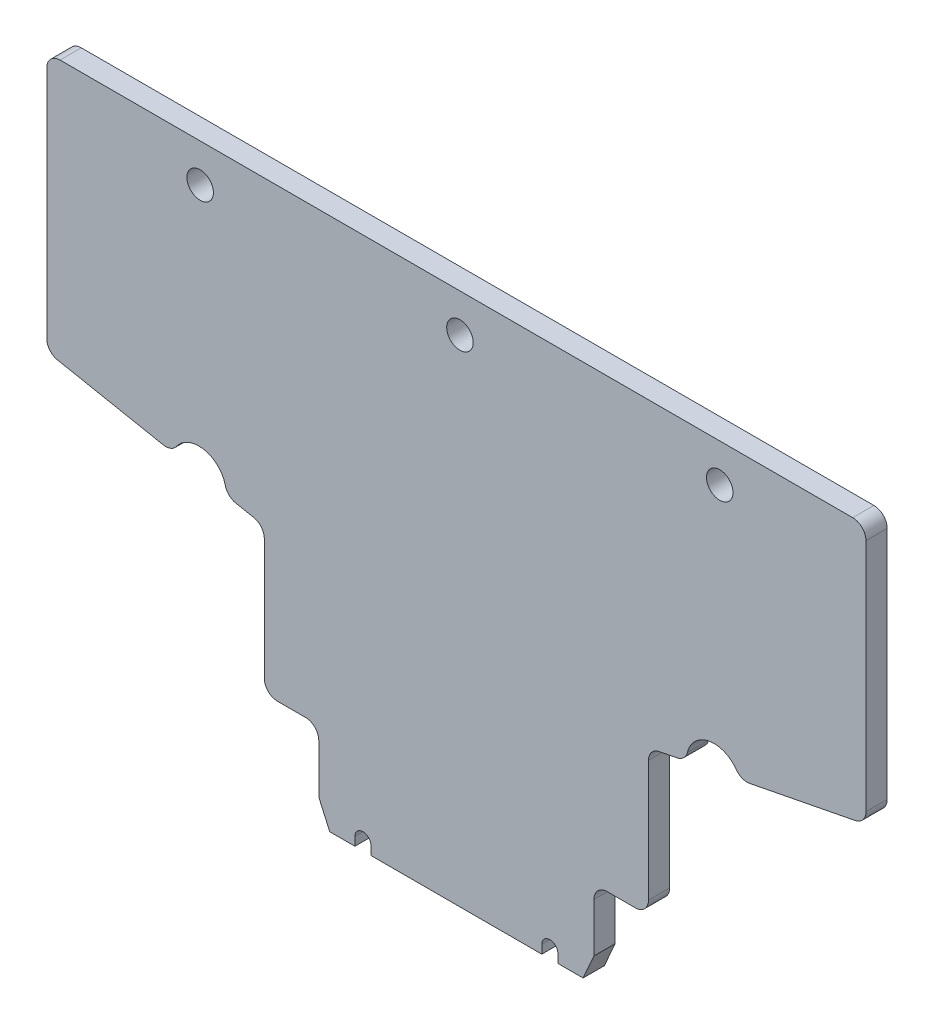
from build123d import *

# Parameters (mm, degrees)
SKETCH1_W           = 80
SKETCH1_H           = 60
BOSS_EXTRUDE1_DEPTH = 1.6
SKETCH2_OUTSIDE_W   = 102.002
SKETCH2_OUTSIDE_H   = 82.002
CUT_EXTRUDE1_DEPTH  = 1.6
FILLET1_R           = 1
SKETCH3_R           = 1
CUT_EXTRUDE2_DEPTH  = 10


with BuildPart() as part:
    # Sketch1 → Boss-Extrude1 (new body)
    with BuildSketch(Plane.XY):
        with Locations((40, 30)):
            Rectangle(SKETCH1_W, SKETCH1_H)
    extrude(amount=BOSS_EXTRUDE1_DEPTH)

    # Sketch2 outside → Cut-Extrude1 (cut)
    with BuildSketch(Plane.XY.offset(1.6)):
        with Locations((40, 30)):
            Rectangle(SKETCH2_OUTSIDE_W, SKETCH2_OUTSIDE_H)
        with BuildLine():
            Line((8.830524125, 49.648617791), (70.632878184, 49.648617791))
            Line((70.632878184, 49.648617791), (70.632878184, 30.112540158))
            Line((70.632878184, 30.112540158), (61.123106489, 28.255784683))
            ThreePointArc((61.123106489, 28.255784683), (58.77201565, 29.627241667), (57.109476194, 27.472134952))
            Line((57.109476194, 27.472134952), (54.224418996, 26.908835862))
            Line((54.224418996, 26.908835862), (54.224418996, 15.955223451))
            Line((54.224418996, 15.955223451), (50.114060899, 15.955223451))
            Line((50.114060899, 15.955223451), (50.114060899, 11.256501231))
            Line((50.114060899, 11.256501231), (49.289397665, 9.401008955))
            Line((49.289397665, 9.401008955), (47.389901446, 9.401008955))
            Line((47.389901446, 9.401008955), (47.389901446, 10.047799846))
            ThreePointArc((47.389901446, 10.047799846), (46.783221619, 10.654479673), (46.176541793, 10.047799846))
            Line((46.176541793, 10.047799846), (46.176541793, 9.401008955))
            Line((46.176541793, 9.401008955), (33.286860516, 9.401008955))
            Line((33.286860516, 9.401008955), (33.286860516, 10.047799846))
            ThreePointArc((33.286860516, 10.047799846), (32.68018069, 10.654479673), (32.073500863, 10.047799846))
            Line((32.073500863, 10.047799846), (32.073500863, 9.401008955))
            Line((32.073500863, 9.401008955), (30.174004644, 9.401008955))
            Line((30.174004644, 9.401008955), (29.34934141, 11.256501231))
            Line((29.34934141, 11.256501231), (29.34934141, 15.955223451))
            Line((29.34934141, 15.955223451), (25.238983313, 15.955223451))
            Line((25.238983313, 15.955223451), (25.238983313, 26.908835862))
            Line((25.238983313, 26.908835862), (22.353926115, 27.472134952))
            ThreePointArc((22.353926115, 27.472134952), (20.691386659, 29.627241667), (18.34029582, 28.255784683))
            Line((18.34029582, 28.255784683), (8.830524125, 30.112540158))
            Line((8.830524125, 30.112540158), (8.830524125, 49.648617791))
        make_face(mode=Mode.SUBTRACT)
    extrude(amount=-CUT_EXTRUDE1_DEPTH, mode=Mode.SUBTRACT)

    # Fillet1
    fillet1_edges = [part.edges().sort_by_distance(p)[0] for p in [
        (8.830524125, 49.648617791, 0.8),
        (70.632878184, 49.648617791, 0.8),
        (70.632878184, 30.112540158, 0.8),
        (61.123106489, 28.255784683, 0.8),
        (57.109476194, 27.472134952, 0.8),
        (54.224418996, 26.908835862, 0.8),
        (54.224418996, 15.955223451, 0.8),
        (50.114060899, 15.955223451, 0.8),
        (29.34934141, 15.955223451, 0.8),
        (25.238983313, 15.955223451, 0.8),
        (25.238983313, 26.908835862, 0.8),
        (22.353926115, 27.472134952, 0.8),
        (18.34029582, 28.255784683, 0.8),
        (8.830524125, 30.112540158, 0.8),
    ]]
    fillet(fillet1_edges, radius=FILLET1_R)

    # Sketch3 → Cut-Extrude2 (cut)
    with BuildSketch(Plane.XY.offset(1.6)):
        with Locations((20.4, 46.768617791)):
            Circle(SKETCH3_R)
        with Locations((40, 46.768617791)):
            Circle(SKETCH3_R)
        with Locations((59.6, 46.768617791)):
            Circle(SKETCH3_R)
    extrude(amount=-CUT_EXTRUDE2_DEPTH, mode=Mode.SUBTRACT)


solid = part.part
